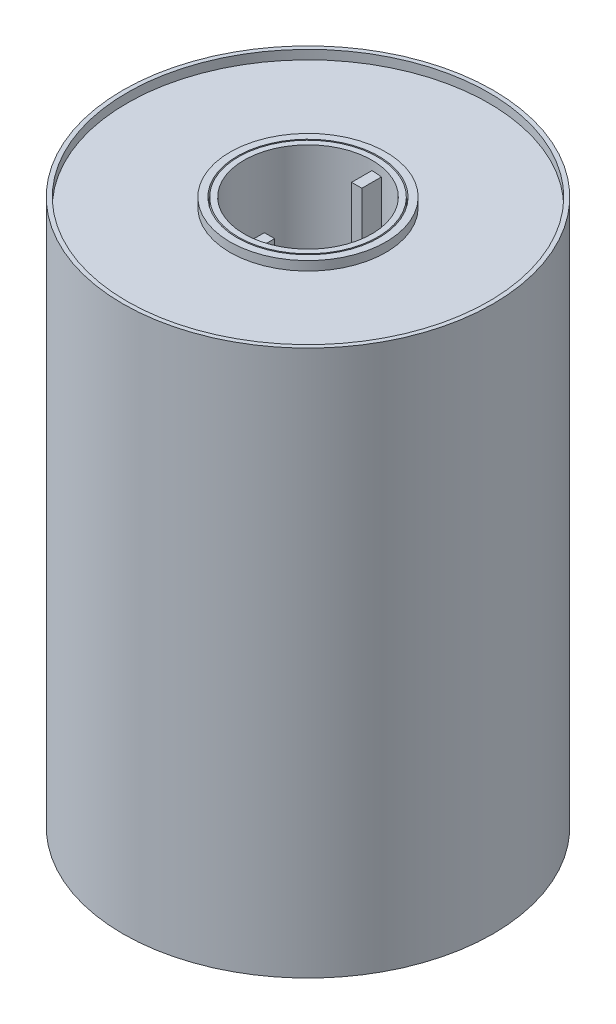
from build123d import *

# Parameters (mm, degrees)
CROQUIS1_R              = 50.89009471
SALIENTE_EXTRUIR1_DEPTH = 150
CROQUIS2_R              = 17.571410618
CORTAR_EXTRUIR1_DEPTH   = 151
CROQUIS3_R              = 49.718427997
CROQUIS3_R_2            = 19.121829202
CORTAR_EXTRUIR2_DEPTH   = 2.5
CROQUIS4_R              = 19.476892412
CROQUIS4_R_2            = 17.829813716
SALIENTE_EXTRUIR3_DEPTH = 15
CROQUIS6_R              = 49.233249933
CROQUIS6_R_2            = 21.531739476
CORTAR_EXTRUIR4_DEPTH   = 5
CROQUIS8_W              = 2.81398907
CROQUIS8_H              = 5.576117682
SALIENTE_EXTRUIR6_DEPTH = 145
CROQUIS9_R              = 21.421140015
CROQUIS9_R_2            = 19.462987184
SALIENTE_EXTRUIR7_DEPTH = 2.5


with BuildPart() as part:
    # Croquis1 → Saliente-Extruir1 (new body)
    with BuildSketch(Plane(origin=(0, 0, 0), x_dir=(1, 0, 0), z_dir=(0, 1, 0))):
        Circle(CROQUIS1_R)
    extrude(amount=SALIENTE_EXTRUIR1_DEPTH)

    # Croquis2 → Cortar-Extruir1 (cut, through all)
    with BuildSketch(Plane(origin=(0, 150, 0), x_dir=(1, 0, 0), z_dir=(0, 1, 0))):
        Circle(CROQUIS2_R)
    extrude(amount=-CORTAR_EXTRUIR1_DEPTH, mode=Mode.SUBTRACT)

    # Croquis3 → Cortar-Extruir2 (cut)
    with BuildSketch(Plane(origin=(0, 150, 0), x_dir=(1, 0, 0), z_dir=(0, 1, 0))):
        Circle(CROQUIS3_R)
        Circle(CROQUIS3_R_2, mode=Mode.SUBTRACT)
    extrude(amount=-CORTAR_EXTRUIR2_DEPTH, mode=Mode.SUBTRACT)

    # Croquis4 → Saliente-Extruir3 (add)
    with BuildSketch(Plane.XZ):
        Circle(CROQUIS4_R)
        Circle(CROQUIS4_R_2, mode=Mode.SUBTRACT)
    extrude(amount=SALIENTE_EXTRUIR3_DEPTH)

    # Croquis6 → Cortar-Extruir4 (cut)
    with BuildSketch(Plane.XZ):
        Circle(CROQUIS6_R)
        Circle(CROQUIS6_R_2, mode=Mode.SUBTRACT)
    extrude(amount=-CORTAR_EXTRUIR4_DEPTH, mode=Mode.SUBTRACT)

    # Croquis8 → Saliente-Extruir6 (add)
    with BuildSketch(Plane(origin=(0, 147.5, 0), x_dir=(1, 0, 0), z_dir=(0, 1, 0))):
        with Locations((1.406994535, 14.783351777)):
            Rectangle(CROQUIS8_W, CROQUIS8_H)
        with Locations((1.406994535, -14.783351777)):
            Rectangle(CROQUIS8_W, CROQUIS8_H)
    extrude(amount=-SALIENTE_EXTRUIR6_DEPTH)

    # Croquis9 → Saliente-Extruir7 (add)
    with BuildSketch(Plane(origin=(0, 147.5, 0), x_dir=(1, 0, 0), z_dir=(0, 1, 0))):
        Circle(CROQUIS9_R)
        Circle(CROQUIS9_R_2, mode=Mode.SUBTRACT)
    extrude(amount=SALIENTE_EXTRUIR7_DEPTH)


solid = part.part
